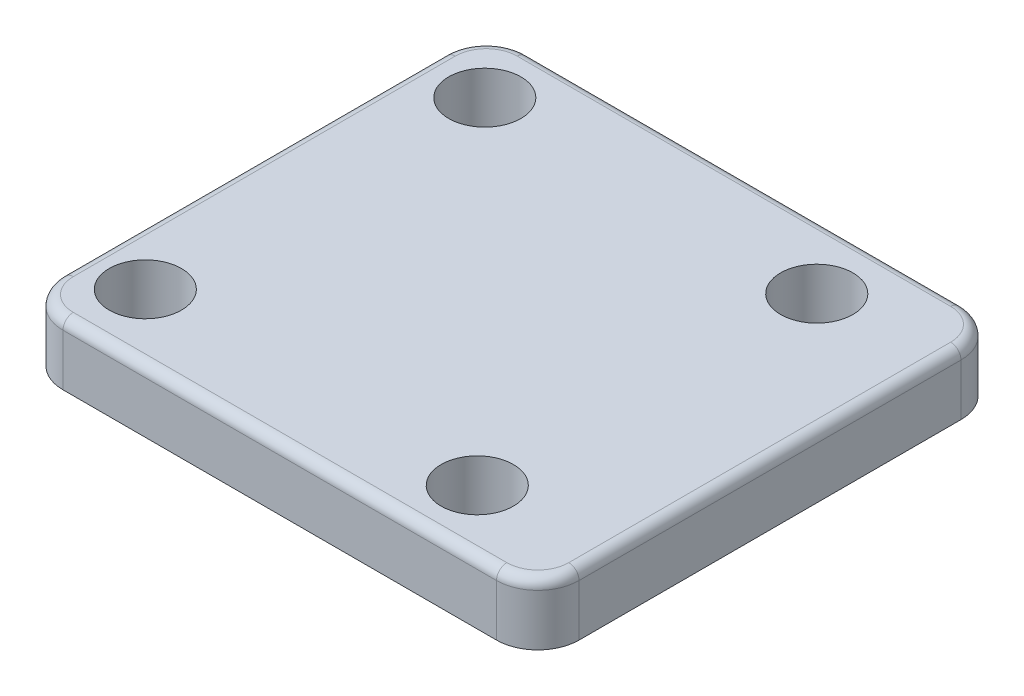
from build123d import *

# Parameters (mm, degrees)
SKETCH1_R           = 3.5
BOSS_EXTRUDE1_DEPTH = 6
FILLET1_R           = 1
SKETCH2_R           = 16
BOSS_EXTRUDE2_DEPTH = 2
CHAMFER1_SIZE       = 1


with BuildPart() as part:
    # Sketch1 → Boss-Extrude1 (new body)
    with BuildSketch(Plane(origin=(0, 0, 0), x_dir=(1, 0, 0), z_dir=(0, 1, 0))):
        with BuildLine():
            Line((-18, 22.5), (24, 22.5))
            ThreePointArc((24, 22.5), (26.828427125, 21.328427125), (28, 18.5))
            Line((28, 18.5), (28, -18.5))
            ThreePointArc((28, -18.5), (26.828427125, -21.328427125), (24, -22.5))
            Line((24, -22.5), (-18, -22.5))
            ThreePointArc((-18, -22.5), (-20.828427125, -21.328427125), (-22, -18.5))
            Line((-22, -18.5), (-22, 18.5))
            ThreePointArc((-22, 18.5), (-20.828427125, 21.328427125), (-18, 22.5))
        make_face()
        with Locations((-16.079705534, 16.445153387)):
            Circle(SKETCH1_R, mode=Mode.SUBTRACT)
        with Locations((16.445153387, 16.079705534)):
            Circle(SKETCH1_R, mode=Mode.SUBTRACT)
        with Locations((16.079705534, -16.445153387)):
            Circle(SKETCH1_R, mode=Mode.SUBTRACT)
        with Locations((-16.445153387, -16.079705534)):
            Circle(SKETCH1_R, mode=Mode.SUBTRACT)
    extrude(amount=BOSS_EXTRUDE1_DEPTH)

    # Fillet1
    fillet1_edges = [part.edges().sort_by_distance(p)[0] for p in [
        (-20.828427125, 6, -21.328427125),
        (-22, 6, 0),
        (-20.828427125, 6, 21.328427125),
        (3, 6, 22.5),
        (26.828427125, 6, 21.328427125),
        (28, 6, 0),
        (26.828427125, 6, -21.328427125),
        (3, 6, -22.5),
    ]]
    fillet(fillet1_edges, radius=FILLET1_R)

    # Sketch2 → Boss-Extrude2 (add)
    with BuildSketch(Plane.XZ):
        Circle(SKETCH2_R)
    extrude(amount=BOSS_EXTRUDE2_DEPTH)

    # Chamfer1
    chamfer1_edges = [part.edges().sort_by_distance(p)[0] for p in [
        (-16, -2, 0),
    ]]
    chamfer(chamfer1_edges, length=CHAMFER1_SIZE)


solid = part.part
